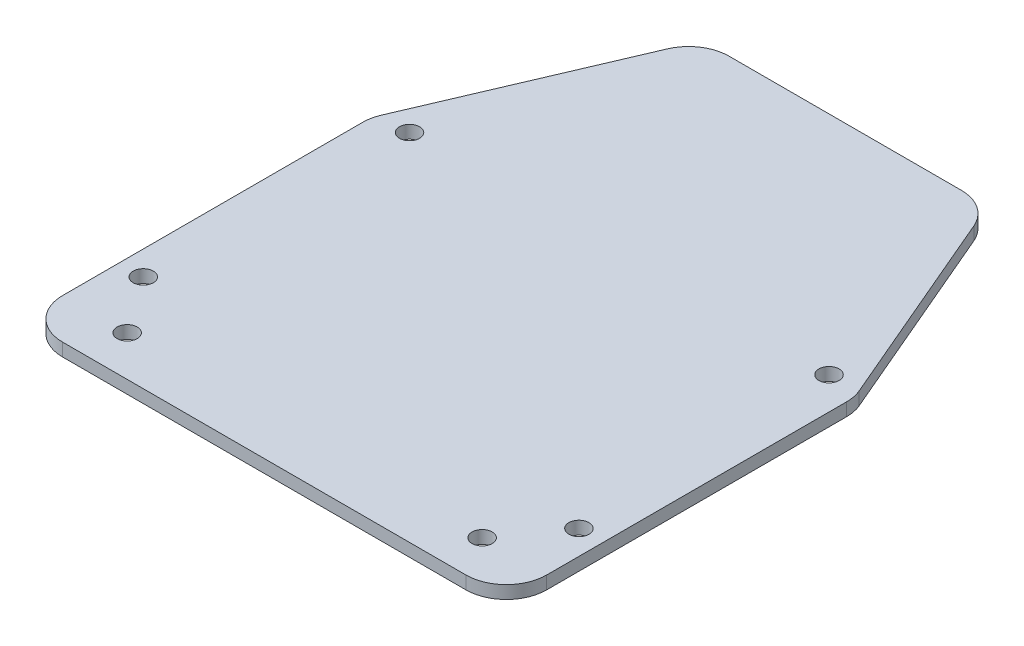
from build123d import *

# Parameters (mm, degrees)
BOSS_EXTRUDE1_DEPTH = 1.6
CUT_EXTRUDE1_START  = 1.6
SKETCH2_R           = 1.25
CUT_EXTRUDE1_DEPTH  = 2.5
FILLET1_R           = 5


with BuildPart() as part:
    # Sketch1 → Boss-Extrude1 (new body)
    with BuildSketch(Plane(origin=(0, 0, 0), x_dir=(1, 0, 0), z_dir=(0, 1, 0))):
        Polygon((17.7, 36), (-17.7, 36), (-30, 7.2), (-30, -36), (30, -36), (30, 7.2), align=None)
    extrude(amount=BOSS_EXTRUDE1_DEPTH)

    # Sketch2 → Cut-Extrude1 (cut)
    with BuildSketch(Plane(origin=(0, 0, 0), x_dir=(1, 0, 0), z_dir=(0, 1, 0)).offset(CUT_EXTRUDE1_START)):
        with Locations((-27, -24)):
            Circle(SKETCH2_R)
        with Locations((27, -24)):
            Circle(SKETCH2_R)
        with Locations((26, 8)):
            Circle(SKETCH2_R)
        with Locations((-26, 8)):
            Circle(SKETCH2_R)
        with Locations((-22, -31)):
            Circle(SKETCH2_R)
        with Locations((22, -31)):
            Circle(SKETCH2_R)
    extrude(amount=-CUT_EXTRUDE1_DEPTH, mode=Mode.SUBTRACT)

    # Fillet1
    fillet1_edges = [part.edges().sort_by_distance(p)[0] for p in [
        (30, 0.8, -7.2),
        (30, 0.8, 36),
        (-30, 0.8, 36),
        (-30, 0.8, -7.2),
        (-17.7, 0.8, -36),
        (17.7, 0.8, -36),
    ]]
    fillet(fillet1_edges, radius=FILLET1_R)


solid = part.part
